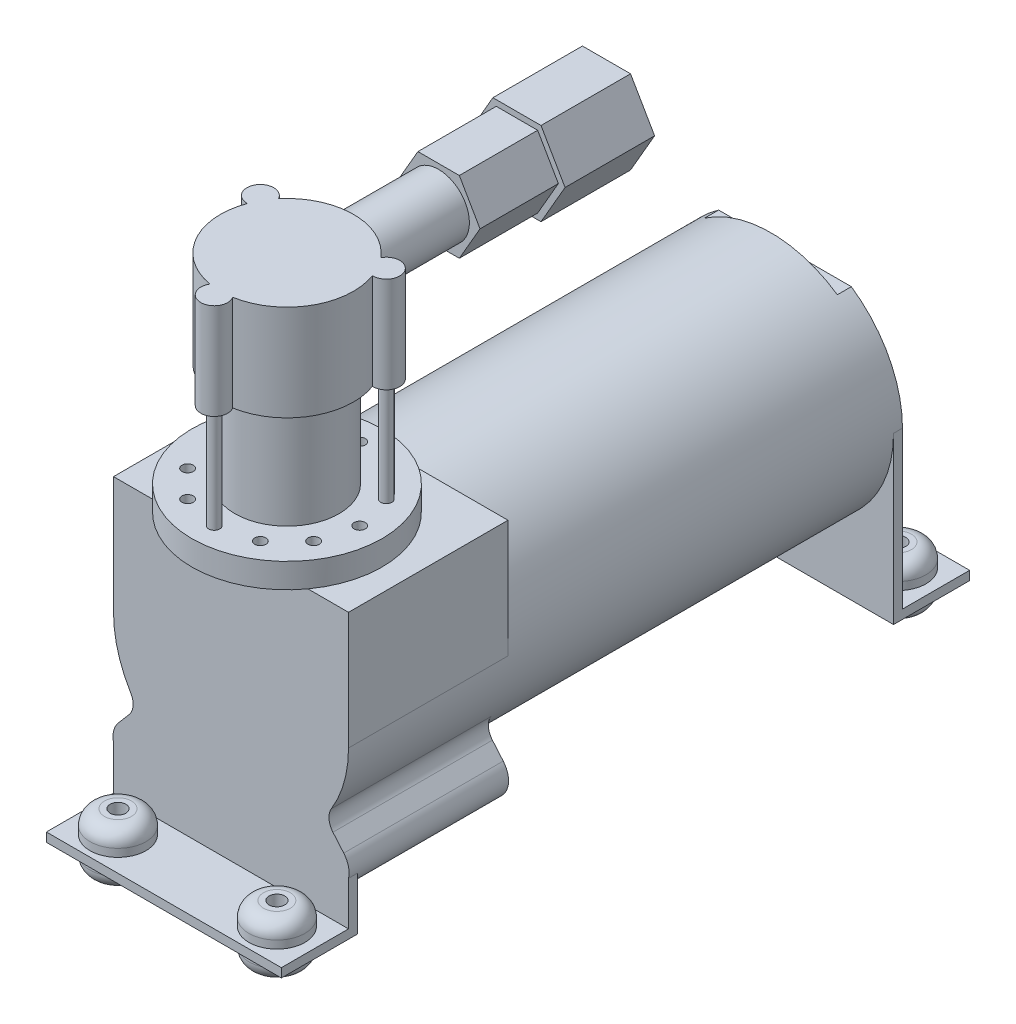
from build123d import *

# Parameters (mm, degrees)
SKETCH1_R               = 26.67
BOSS_EXTRUDE1_DEPTH     = 62.865
BOSS_EXTRUDE2_DEPTH     = 36.195
BOSS_EXTRUDE4_DEPTH     = 2.032
SKETCH7_W               = 53.34
SKETCH7_H               = 2.032
BOSS_EXTRUDE5_DEPTH     = 15.24
BOSS_EXTRUDE6_DEPTH     = 2.032
CUT_EXTRUDE1_DEPTH      = 3.175
SKETCH11_R              = 12.7
BOSS_EXTRUDE7_DEPTH     = 3.302
SKETCH12_R              = 1.778
CUT_EXTRUDE2_DEPTH      = 3.032
SKETCH13_W              = 4.572
SKETCH13_H              = 5.08
MIRROR4_COPY_1_SKETCH_W = 4.572
MIRROR4_COPY_1_SKETCH_H = 5.08
FILLET2_R               = 3.302
SKETCH14_R              = 21.59
SKETCH14_R_2            = 11.811
BOSS_EXTRUDE8_DEPTH     = 5.588
SKETCH15_R              = 1.27
CUT_EXTRUDE3_DEPTH      = 5.588
CIRPATTERN1_COUNT       = 12
SKETCH16_R              = 11.811
SKETCH16_R_2            = 1.27
BOSS_EXTRUDE9_DEPTH     = 29.21
BOSS_EXTRUDE10_DEPTH    = 21.7678
BOSS_EXTRUDE11_START    = -1.71104
SKETCH19_R              = 6.985
BOSS_EXTRUDE11_DEPTH    = 21.01504
BOSS_EXTRUDE12_DEPTH    = 17.78
SKETCH23_R              = 5.715
BOSS_EXTRUDE15_DEPTH    = 20.32


with BuildPart() as part:
    # Sketch1 → Boss-Extrude1 (new body, symmetric)
    with BuildSketch(Plane.XY):
        Circle(SKETCH1_R)
    extrude(amount=BOSS_EXTRUDE1_DEPTH, both=True)

    # Sketch2 → Boss-Extrude2 (add)
    with BuildSketch(Plane.XY.offset(62.865)):
        with BuildLine():
            Line((26.67, 26.67), (0, 26.67))
            ThreePointArc((0, 26.67), (18.858537854, 18.858537854), (26.67, 0))
            Line((26.67, 0), (26.67, 26.67))
        make_face()
        with BuildLine():
            ThreePointArc((23.129196088, -18.326331253), (22.232442946, -16.15759753), (22.77673696, -13.87476679))
            ThreePointArc((22.77673696, -13.87476679), (17.688958427, -19.959700643), (11.036631134, -24.279243671))
            ThreePointArc((11.036631134, -24.279243671), (13.368332341, -24.013270658), (15.413562996, -25.164184959))
            Line((15.413562996, -25.164184959), (17.983306305, -27.949520455))
            ThreePointArc((17.983306305, -27.949520455), (25.086325415, -28.306672072), (25.585480583, -21.212217768))
            Line((25.585480583, -21.212217768), (23.129196088, -18.326331253))
        make_face()
    boss_extrude2 = extrude(amount=-BOSS_EXTRUDE2_DEPTH)

    # Mirror1: Boss-Extrude2 across plane
    add(boss_extrude2.mirror(Plane(origin=(0, 0, 0), x_dir=(0, 0, 1), z_dir=(1, 0, 0))))

    # Sketch6 → Boss-Extrude4 (add)
    with BuildSketch(Plane(origin=(0, 0, -62.865), x_dir=(-1, 0, 0), z_dir=(0, 0, -1))):
        with BuildLine():
            Line((-26.67, 0), (-26.67, -37.592))
            Line((-26.67, -37.592), (26.67, -37.592))
            Line((26.67, -37.592), (26.67, 0))
            ThreePointArc((26.67, 0), (0, -26.67), (-26.67, 0))
        make_face()
    extrude(amount=-BOSS_EXTRUDE4_DEPTH)

    # Sketch7 → Boss-Extrude5 (add)
    with BuildSketch(Plane(origin=(0, 0, -62.865), x_dir=(-1, 0, 0), z_dir=(0, 0, -1))):
        with Locations((0, -36.576)):
            Rectangle(SKETCH7_W, SKETCH7_H)
    boss_extrude5 = extrude(amount=BOSS_EXTRUDE5_DEPTH)

    # Sketch9 → Boss-Extrude6 (add)
    with BuildSketch(Plane.XY.offset(62.865)):
        with BuildLine():
            Line((-15.413562996, -25.164184959), (-17.983306305, -27.949520455))
            ThreePointArc((-17.983306305, -27.949520455), (-23.025632829, -29.413376064), (-26.67, -25.633625022))
            Line((-26.67, -25.633625022), (-26.67, -37.592))
            Line((-26.67, -37.592), (26.67, -37.592))
            Line((26.67, -37.592), (26.67, -25.633625022))
            ThreePointArc((26.67, -25.633625022), (23.025632829, -29.413376064), (17.983306305, -27.949520455))
            Line((17.983306305, -27.949520455), (15.413562996, -25.164184959))
            ThreePointArc((15.413562996, -25.164184959), (13.368332341, -24.013270658), (11.036631134, -24.279243671))
            ThreePointArc((11.036631134, -24.279243671), (0, -26.67), (-11.036631134, -24.279243671))
            ThreePointArc((-11.036631134, -24.279243671), (-13.368332341, -24.013270658), (-15.413562996, -25.164184959))
        make_face()
    extrude(amount=-BOSS_EXTRUDE6_DEPTH)

    # Mirror2: Boss-Extrude5 across plane
    add(boss_extrude5.mirror(Plane.XY))

    # Sketch10 → Cut-Extrude1 (cut)
    with BuildSketch(Plane(origin=(0, 0, -62.865), x_dir=(-1, 0, 0), z_dir=(0, 0, -1))):
        with BuildLine():
            Line((-15.062815713, 22.0091), (15.062815713, 22.0091))
            ThreePointArc((15.062815713, 22.0091), (0, 26.67), (-15.062815713, 22.0091))
        make_face()
    extrude(amount=-CUT_EXTRUDE1_DEPTH, mode=Mode.SUBTRACT)

    # Sketch11 → Boss-Extrude7 (add)
    with BuildSketch(Plane(origin=(0, 0, -62.865), x_dir=(-1, 0, 0), z_dir=(0, 0, -1))):
        Circle(SKETCH11_R)
    extrude(amount=BOSS_EXTRUDE7_DEPTH)

    # Sketch12 → Cut-Extrude2 (cut, through all)
    with BuildSketch(Plane(origin=(0, -35.56, 0), x_dir=(1, 0, 0), z_dir=(0, 1, 0))):
        with Locations((-18.034, -70.485)):
            Circle(SKETCH12_R)
        with Locations((18.034, -70.485)):
            Circle(SKETCH12_R)
    extrude(amount=-CUT_EXTRUDE2_DEPTH, mode=Mode.SUBTRACT)

    # Sketch13 → Revolve1 (revolve)
    with BuildSketch(Plane.XY.offset(70.485)):
        with Locations((22.098, -33.02)):
            Rectangle(SKETCH13_W, SKETCH13_H)
        with Locations((22.098, -40.132)):
            Rectangle(SKETCH13_W, SKETCH13_H)
    revolve1 = revolve(axis=Axis((18.034, -35.56, 70.485), (0, 1, 0)))

    # Mirror3: Revolve1 across plane
    add(revolve1.mirror(Plane(origin=(0, 0, 0), x_dir=(0, 0, 1), z_dir=(1, 0, 0))))

    # Mirror4: Revolve1 across plane
    add(revolve1.mirror(Plane.XY))

    # Mirror4 copy 1 sketch → Mirror4 copy 1 (revolve)
    with BuildSketch(Plane(origin=(0, 0, -70.485), x_dir=(-1, 0, 0), z_dir=(0, 0, -1))):
        with Locations((22.098, -33.02)):
            Rectangle(MIRROR4_COPY_1_SKETCH_W, MIRROR4_COPY_1_SKETCH_H)
        with Locations((22.098, -40.132)):
            Rectangle(MIRROR4_COPY_1_SKETCH_W, MIRROR4_COPY_1_SKETCH_H)
    revolve(axis=Axis((-18.034, -35.56, -70.485), (0, 1, 0)))

    # Fillet2
    fillet2_edges = [part.edges().sort_by_distance(p)[0] for p in [
        (11.684, -30.48, 70.485),
        (11.684, -42.672, 70.485),
        (-11.684, -30.48, 70.485),
        (-11.684, -42.672, 70.485),
        (-11.684, -30.48, -70.485),
        (-11.684, -42.672, -70.485),
        (11.684, -30.48, -70.485),
        (11.684, -42.672, -70.485),
    ]]
    fillet(fillet2_edges, radius=FILLET2_R)

    # Sketch14 → Boss-Extrude8 (add)
    with BuildSketch(Plane(origin=(0, 26.67, 0), x_dir=(1, 0, 0), z_dir=(0, 1, 0))):
        with Locations((0, -50.165)):
            Circle(SKETCH14_R)
        with Locations((0, -50.165)):
            Circle(SKETCH14_R_2, mode=Mode.SUBTRACT)
    extrude(amount=BOSS_EXTRUDE8_DEPTH)

    # Sketch15 → Cut-Extrude3 (cut)
    with BuildSketch(Plane(origin=(0, 32.258, 0), x_dir=(1, 0, 0), z_dir=(0, 1, 0))):
        with Locations((0, -33.655)):
            Circle(SKETCH15_R)
    cut_extrude3 = extrude(amount=-CUT_EXTRUDE3_DEPTH, mode=Mode.SUBTRACT)

    # CirPattern1: Cut-Extrude3 ×12 about axis
    cirpattern1_axis = Axis((0, 0, 50.165), (0, 1, 0))
    for i in range(1, CIRPATTERN1_COUNT):
        add(cut_extrude3.rotate(cirpattern1_axis, i * 360 / CIRPATTERN1_COUNT), mode=Mode.SUBTRACT)

    # Sketch16 → Boss-Extrude9 (add)
    with BuildSketch(Plane(origin=(0, 26.67, 0), x_dir=(1, 0, 0), z_dir=(0, 1, 0))):
        with Locations((0, -50.165)):
            Circle(SKETCH16_R)
        with Locations((0, -66.675)):
            Circle(SKETCH16_R_2)
        with Locations((-14.298079416, -41.91)):
            Circle(SKETCH16_R_2)
        with Locations((14.298079416, -41.91)):
            Circle(SKETCH16_R_2)
    extrude(amount=BOSS_EXTRUDE9_DEPTH)

    # Sketch18 → Boss-Extrude10 (add)
    with BuildSketch(Plane(origin=(0, 55.88, 0), x_dir=(1, 0, 0), z_dir=(0, 1, 0))):
        with BuildLine():
            ThreePointArc((2.582311646, -65.05575), (13.088241927, -57.7215), (14.186923604, -44.955972486))
            ThreePointArc((14.186923604, -44.955972486), (16.937724847, -40.386), (11.604611958, -40.483277514))
            ThreePointArc((11.604611958, -40.483277514), (0, -35.052), (-11.604611958, -40.483277514))
            ThreePointArc((-11.604611958, -40.483277514), (-16.937724847, -40.386), (-14.186923604, -44.955972486))
            ThreePointArc((-14.186923604, -44.955972486), (-13.088241927, -57.7215), (-2.582311646, -65.05575))
            ThreePointArc((-2.582311646, -65.05575), (0, -69.723), (2.582311646, -65.05575))
        make_face()
    extrude(amount=BOSS_EXTRUDE10_DEPTH)

    # Sketch19 → Boss-Extrude11 (add)
    with BuildSketch(Plane(origin=(0, 0, 35.052), x_dir=(-1, 0, 0), z_dir=(0, 0, -1)).offset(BOSS_EXTRUDE11_START)):
        with Locations((0, 69.85)):
            Circle(SKETCH19_R)
    extrude(amount=BOSS_EXTRUDE11_DEPTH)

    # Sketch20 → Boss-Extrude12 (add)
    with BuildSketch(Plane(origin=(0, 0, 15.748), x_dir=(-1, 0, 0), z_dir=(0, 0, -1))):
        Polygon((4.699, 61.711093255), (9.398, 69.85), (4.699, 77.988906745), (-4.699, 77.988906745), (-9.398, 69.85), (-4.699, 61.711093255), align=None)
    extrude(amount=BOSS_EXTRUDE12_DEPTH)

    # Sketch23 → Boss-Extrude15 (add)
    with BuildSketch(Plane(origin=(0, 0, -2.032), x_dir=(-1, 0, 0), z_dir=(0, 0, -1))):
        Polygon((10.922, 69.85), (5.461, 79.30872946), (-5.461, 79.30872946), (-10.922, 69.85), (-5.461, 60.39127054), (5.461, 60.39127054), align=None)
        with Locations((0, 69.85)):
            Circle(SKETCH23_R, mode=Mode.SUBTRACT)
    extrude(amount=BOSS_EXTRUDE15_DEPTH)


solid = part.part
